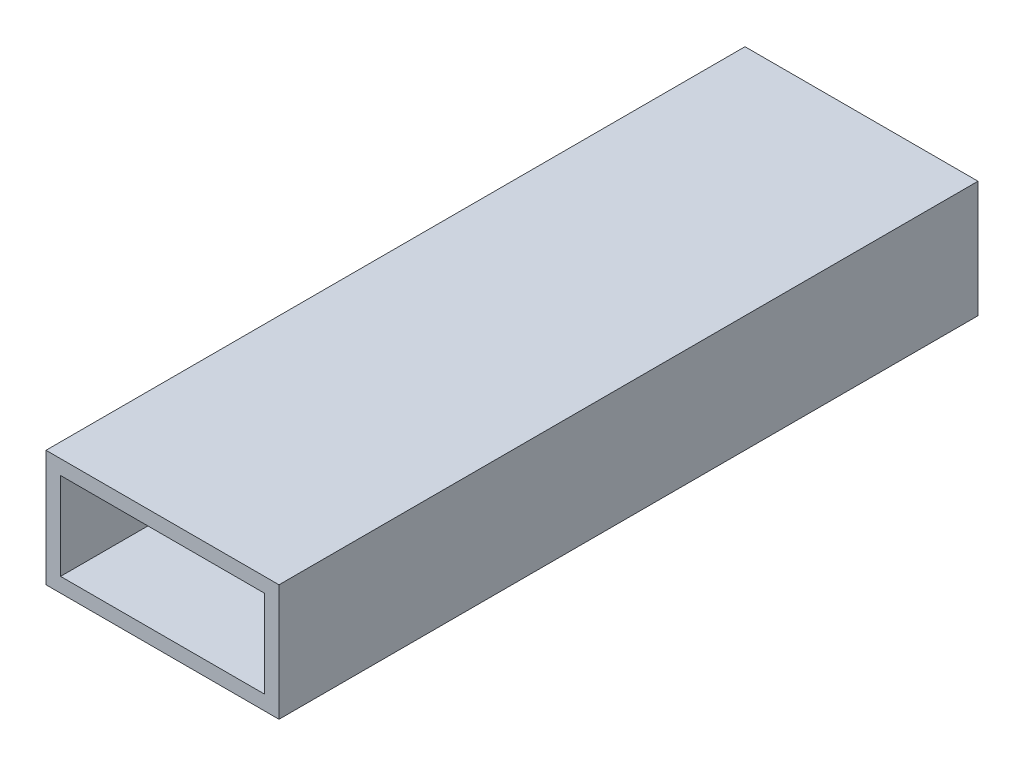
from build123d import *

# Parameters (mm, degrees)
SKETCH1_W           = 50.8
SKETCH1_H           = 25.4
SKETCH1_W_2         = 44.45
SKETCH1_H_2         = 19.05
BOSS_EXTRUDE1_DEPTH = 152.4


with BuildPart() as part:
    # Sketch1 → Boss-Extrude1 (new body)
    with BuildSketch(Plane.XY):
        Rectangle(SKETCH1_W, SKETCH1_H)
        Rectangle(SKETCH1_W_2, SKETCH1_H_2, mode=Mode.SUBTRACT)
    extrude(amount=BOSS_EXTRUDE1_DEPTH)


solid = part.part
